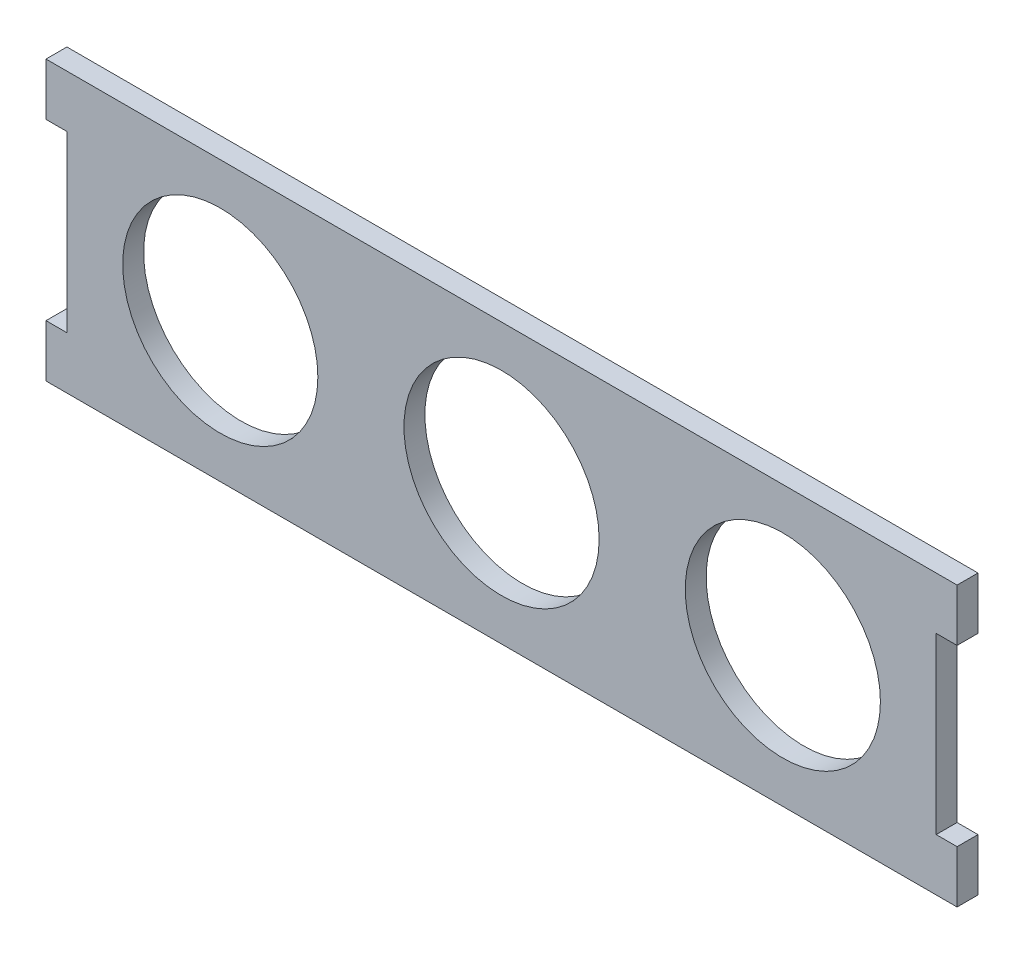
from build123d import *

# Parameters (mm, degrees)
SKETCH1_R           = 14
BOSS_EXTRUDE1_DEPTH = 3


with BuildPart() as part:
    # Sketch1 → Boss-Extrude1 (new body)
    with BuildSketch(Plane.XY):
        Polygon((130.7, 0), (0, 0), (0, -7.5), (3, -7.5), (3, -32.5), (0, -32.5), (0, -40), (130.7, -40), (130.7, -32.5), (127.7, -32.5), (127.7, -7.5), (130.7, -7.5), align=None)
        with Locations((25, -20)):
            Circle(SKETCH1_R, mode=Mode.SUBTRACT)
        with Locations((65.35, -20)):
            Circle(SKETCH1_R, mode=Mode.SUBTRACT)
        with Locations((105.7, -20)):
            Circle(SKETCH1_R, mode=Mode.SUBTRACT)
    extrude(amount=BOSS_EXTRUDE1_DEPTH)


solid = part.part
